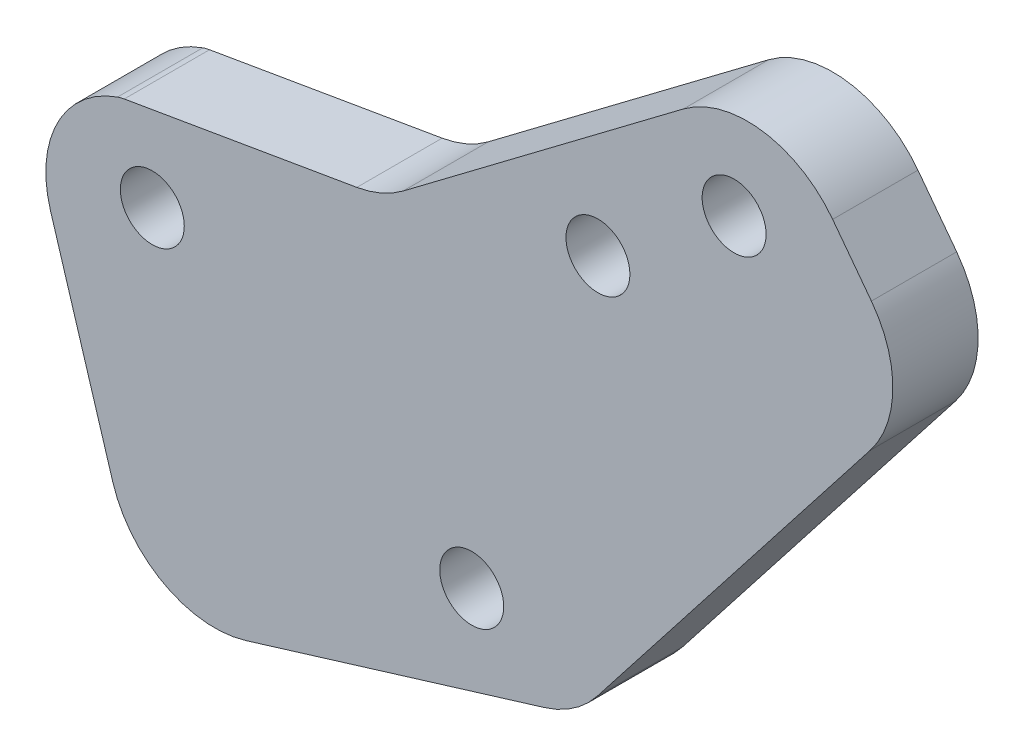
from build123d import *

# Parameters (mm, degrees)
SKETCH_1_R          = 1.5
EXTRUDE_1_DEPTH     = 4
FILLET_2_R          = 5
CUT_EXTRUDE_1_DEPTH = 5
FILLET_3_R          = 5
FILLET_4_R          = 2


with BuildPart() as part:
    # 草图1 → 凸台-拉伸1 (new body)
    with BuildSketch(Plane.XY):
        with BuildLine():
            Line((12.667454416, 18.14297047), (-5.445003471, 4.494254472))
            Line((-5.445003471, 4.494254472), (-17.69465686, 2.402060789))
            ThreePointArc((-17.69465686, 2.402060789), (-20.647536301, -0.032105177), (-21.014322116, -3.841321514))
            Line((-21.014322116, -3.841321514), (-18.090605069, -13.404369074))
            ThreePointArc((-18.090605069, -13.404369074), (-15.656439103, -16.357248515), (-11.847222766, -16.72403433))
            Line((-11.847222766, -16.72403433), (29.431618129, -4.103826174))
            Line((29.431618129, -4.103826174), (12.667454416, 18.14297047))
        make_face()
        with Locations((11.05402554, 11.9758622)):
            Circle(SKETCH_1_R, mode=Mode.SUBTRACT)
        with Locations((4.66494146, 7.161342014)):
            Circle(SKETCH_1_R, mode=Mode.SUBTRACT)
        with Locations((-16.238278615, -1.335446723)):
            Circle(SKETCH_1_R, mode=Mode.SUBTRACT)
        with Locations((-1.254161086, -9.302643338)):
            Circle(SKETCH_1_R, mode=Mode.SUBTRACT)
    extrude(amount=EXTRUDE_1_DEPTH)

    # 圆角2
    fillet_2_edges = [part.edges().sort_by_distance(p)[0] for p in [
        (-5.445003471, 4.494254472, 2),
        (12.667454416, 18.14297047, 2),
    ]]
    fillet(fillet_2_edges, radius=FILLET_2_R)

    # 草图2 → 切除-拉伸1 (cut, through all)
    with BuildSketch(Plane(origin=(0, 0, 0), x_dir=(-1, 0, 0), z_dir=(0, 0, -1))):
        Polygon((-19.802577759, 8.674341987), (-3.664326363, -11.981677845), (-29.431618129, -4.103826174), align=None)
    extrude(amount=-CUT_EXTRUDE_1_DEPTH, mode=Mode.SUBTRACT)

    # 圆角3
    fillet_3_edges = [part.edges().sort_by_distance(p)[0] for p in [
        (19.802577759, 8.674341987, 2),
        (3.664326363, -11.981677845, 2),
    ]]
    fillet(fillet_3_edges, radius=FILLET_3_R)

    # 圆角4
    fillet_4_edges = [part.edges().sort_by_distance(p)[0] for p in [
        (-17.69465686, 2.402060789, 2),
    ]]
    fillet(fillet_4_edges, radius=FILLET_4_R)


solid = part.part
